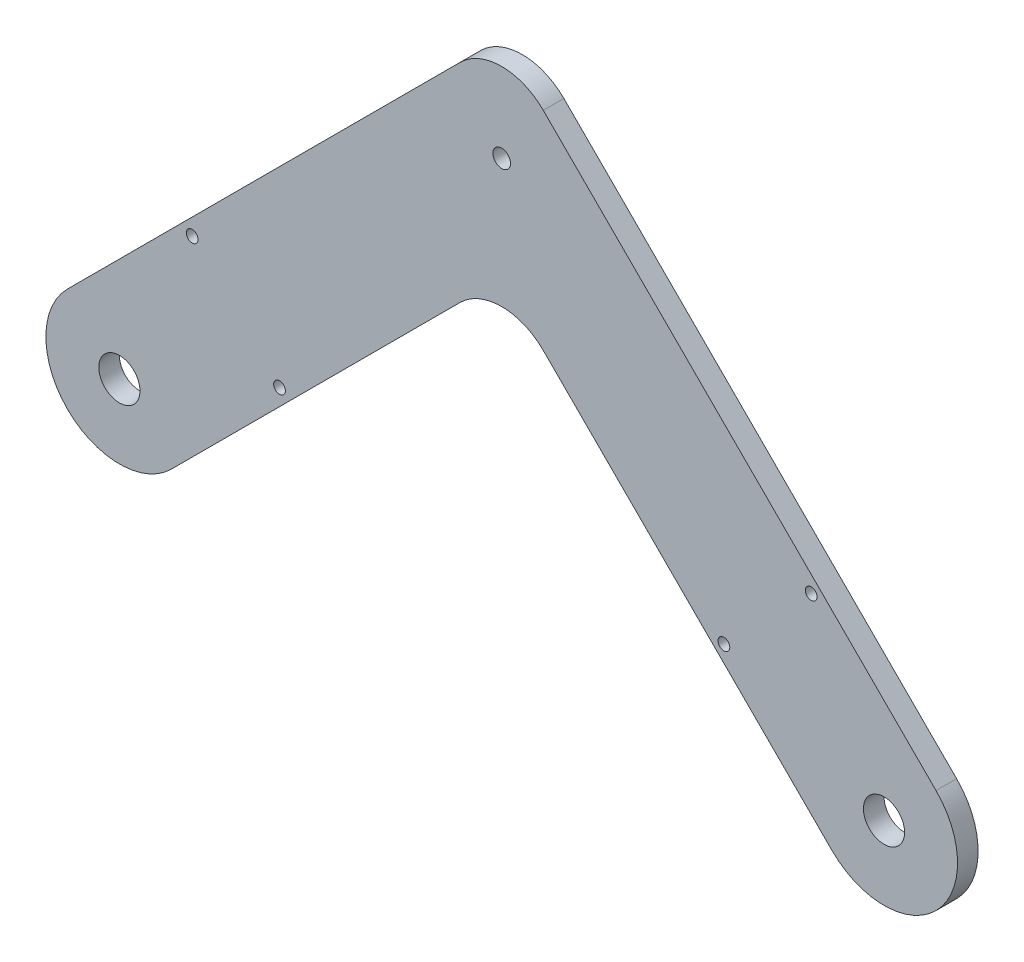
from build123d import *

# Parameters (mm, degrees)
SKETCH2_R           = 3.5
SKETCH2_R_2         = 1.5
BOSS_EXTRUDE1_DEPTH = 3.5
FILLET1_R           = 10
SKETCH3_R           = 1
CUT_EXTRUDE1_DEPTH  = 10


with BuildPart() as part:
    # Sketch2 → Boss-Extrude1 (new body)
    with BuildSketch(Plane.XY):
        with BuildLine():
            Line((-56.161165235, -8.838834765), (0, 47.32233047))
            Line((0, 47.32233047), (56.161165235, -8.838834765))
            ThreePointArc((56.161165235, -8.838834765), (73.838834765, -8.838834765), (73.838834765, 8.838834765))
            Line((73.838834765, 8.838834765), (0, 82.67766953))
            Line((0, 82.67766953), (-73.838834765, 8.838834765))
            ThreePointArc((-73.838834765, 8.838834765), (-73.838834765, -8.838834765), (-56.161165235, -8.838834765))
        make_face()
        with Locations((-65, 0)):
            Circle(SKETCH2_R, mode=Mode.SUBTRACT)
        with Locations((65, 0)):
            Circle(SKETCH2_R, mode=Mode.SUBTRACT)
        with Locations((0, 65)):
            Circle(SKETCH2_R_2, mode=Mode.SUBTRACT)
    extrude(amount=-BOSS_EXTRUDE1_DEPTH)

    # Fillet1
    fillet1_edges = [part.edges().sort_by_distance(p)[0] for p in [
        (0, 82.67766953, -1.75),
        (0, 47.32233047, -1.75),
    ]]
    fillet(fillet1_edges, radius=FILLET1_R)

    # Sketch3 → Cut-Extrude1 (cut)
    with BuildSketch(Plane.XY):
        with Locations((-52.625631329, 27.223611076)):
            Circle(SKETCH3_R)
        with Locations((-37.776388924, 12.374368671)):
            Circle(SKETCH3_R)
        with Locations((37.776388924, 12.374368671)):
            Circle(SKETCH3_R)
        with Locations((52.625631329, 27.223611076)):
            Circle(SKETCH3_R)
    extrude(amount=-CUT_EXTRUDE1_DEPTH, mode=Mode.SUBTRACT)


solid = part.part
